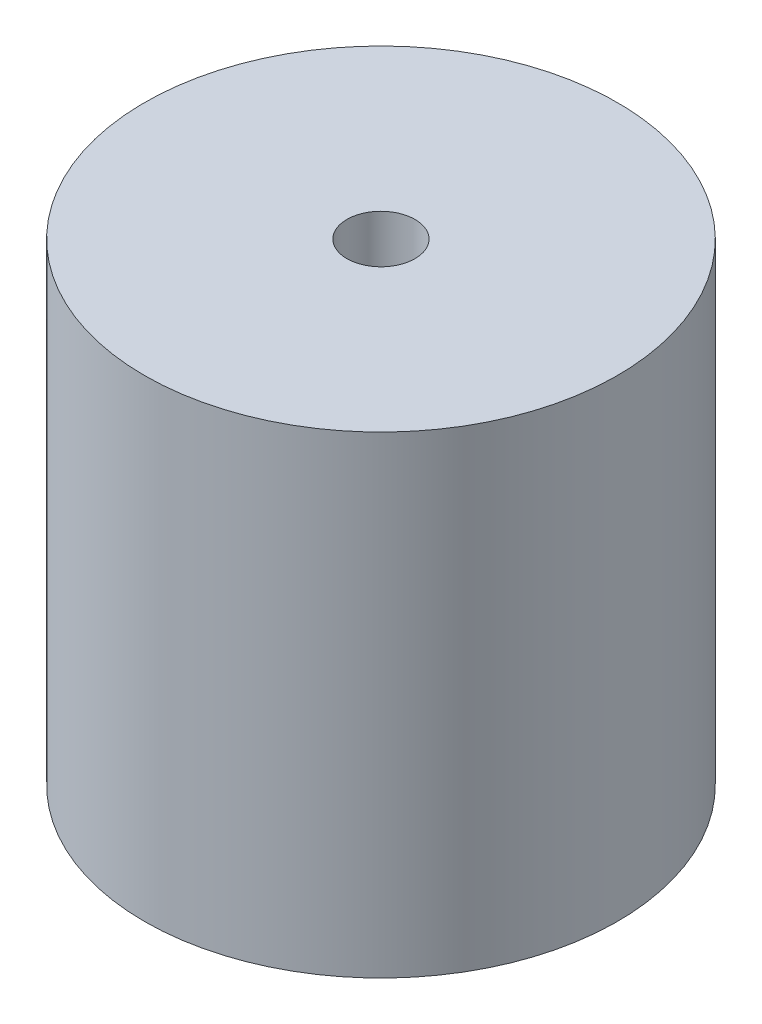
from build123d import *

# Parameters (mm, degrees)
SKETCH1_R           = 12.7
SKETCH1_R_2         = 1.8288
BOSS_EXTRUDE1_DEPTH = 25.4


with BuildPart() as part:
    # Sketch1 → Boss-Extrude1 (new body)
    with BuildSketch(Plane(origin=(0, 0, 0), x_dir=(1, 0, 0), z_dir=(0, 1, 0))):
        Circle(SKETCH1_R)
        Circle(SKETCH1_R_2, mode=Mode.SUBTRACT)
    extrude(amount=BOSS_EXTRUDE1_DEPTH)


solid = part.part
